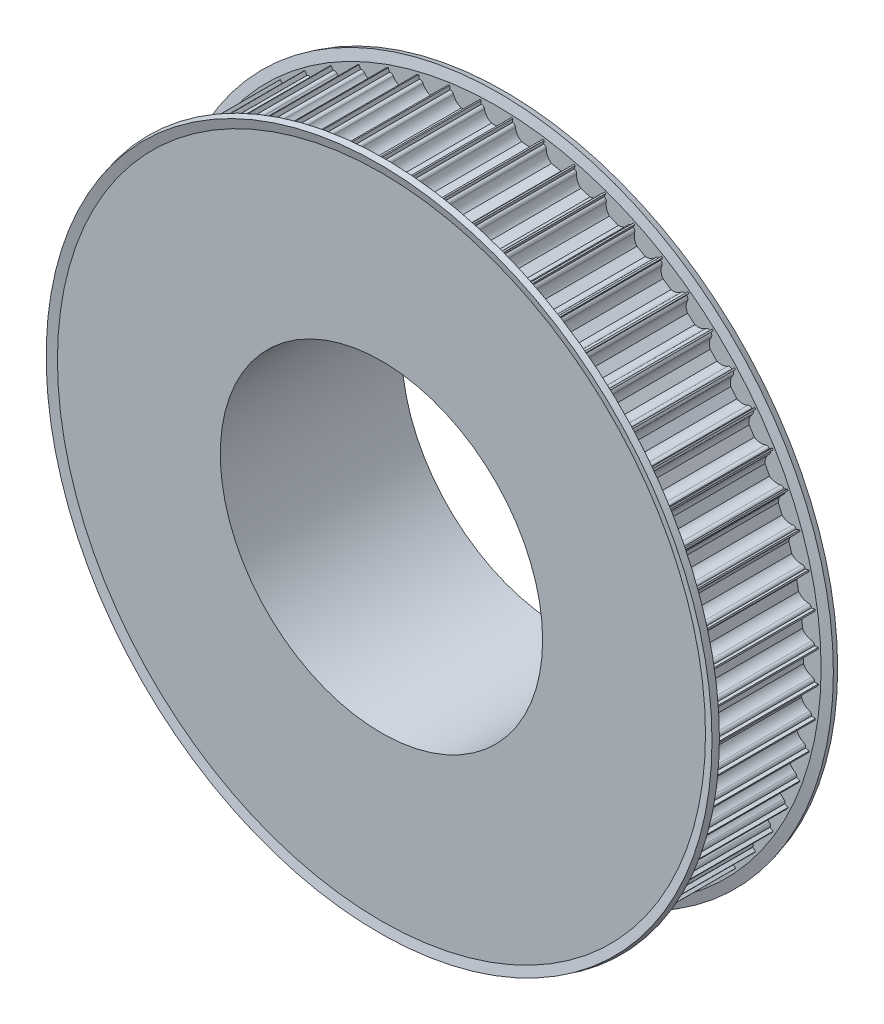
from build123d import *

# Parameters (mm, degrees)
CUT_EXTRUDE1_DEPTH = 30
CIRPATTERN1_COUNT  = 64


with BuildPart() as part:
    # Sketch1 → Revolve1 (revolve)
    with BuildSketch(Plane(origin=(0, 0, 0), x_dir=(0, 0, -1), z_dir=(1, 0, 0))):
        Polygon((0, 40), (45, 40), (45, 55.5), (30, 55.5), (30, 80), (0, 80), align=None)
    revolve(axis=Axis((0, 0, 0), (0, 0, -1)))

    # Sketch2 → Cut-Extrude1 (cut)
    with BuildSketch(Plane.XY):
        with BuildLine():
            Line((-3.674234614, 79), (-3.75, 79))
            Line((-3.75, 79), (-3.75, 81))
            Line((-3.75, 81), (3.75, 81))
            Line((3.75, 81), (3.75, 79))
            Line((3.75, 79), (3.674234614, 79))
            ThreePointArc((3.674234614, 79), (3.199892965, 78.830947502), (2.939387691, 78.4))
            ThreePointArc((2.939387691, 78.4), (2.331759211, 77.112435701), (1.198957881, 76.25))
            Line((1.198957881, 76.25), (-1.198957881, 76.25))
            ThreePointArc((-1.198957881, 76.25), (-2.331759211, 77.112435701), (-2.939387691, 78.4))
            ThreePointArc((-2.939387691, 78.4), (-3.199892965, 78.830947502), (-3.674234614, 79))
        make_face()
    cut_extrude1 = extrude(amount=-CUT_EXTRUDE1_DEPTH, mode=Mode.SUBTRACT)

    # CirPattern1: Cut-Extrude1 ×64 about axis
    cirpattern1_axis = Axis((0, 0, 0), (0, 0, 1))
    for i in range(1, CIRPATTERN1_COUNT):
        add(cut_extrude1.rotate(cirpattern1_axis, i * 360 / CIRPATTERN1_COUNT), mode=Mode.SUBTRACT)

    # Sketch3 → Revolve2 (revolve)
    with BuildSketch(Plane(origin=(0, 0, 0), x_dir=(0, 0, -1), z_dir=(1, 0, 0))):
        Polygon((30, 55.5), (30, 80.412521254), (30.591966801, 82.621771432), (29.143078062, 83.01), (28.5, 80.61), (28.5, 55.5), align=None)
        Polygon((1.5, 55.5), (0, 55.5), (0, 80.412521254), (-0.591966801, 82.621771432), (0.856921938, 83.01), (1.5, 80.61), align=None)
    revolve(axis=Axis((0, 0, 0), (0, 0, -1)))


solid = part.part
